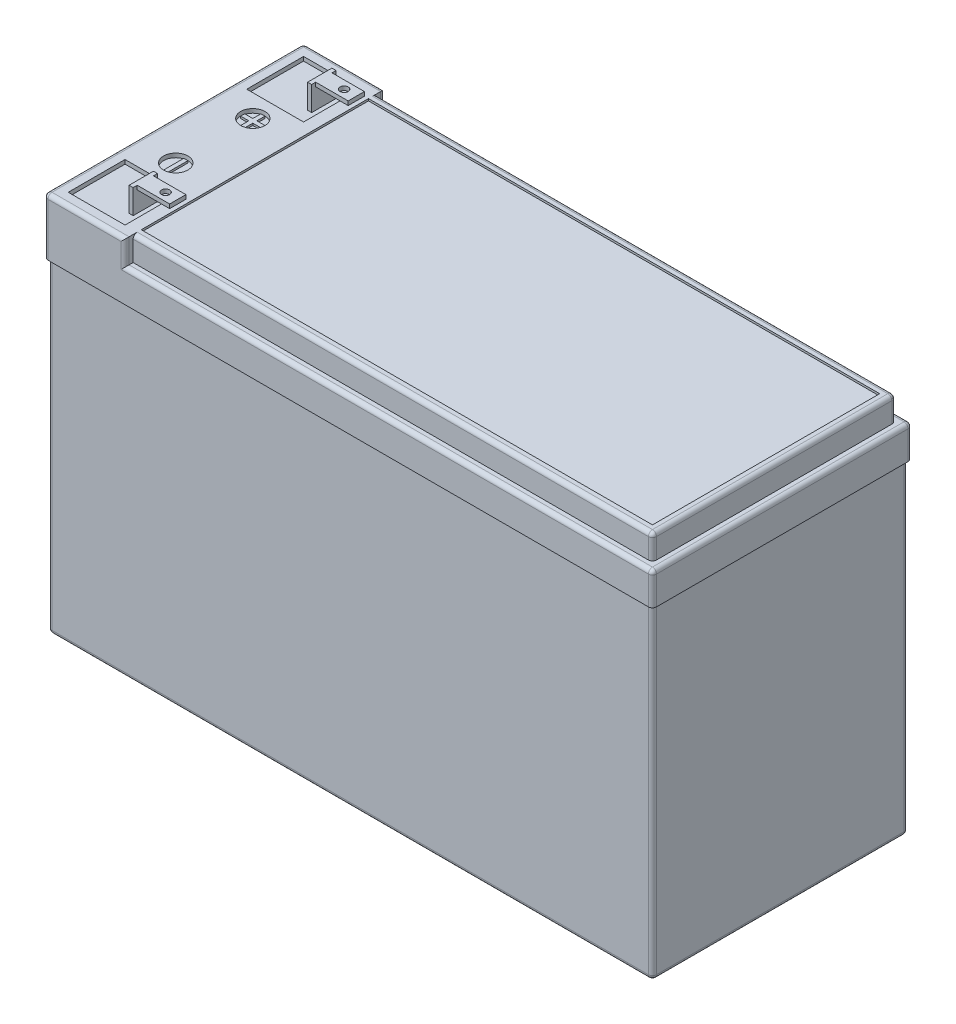
from build123d import *

# Parameters (mm, degrees)
SKETCH1_W           = 150
SKETCH1_H           = 64
BOSS_EXTRUDE1_DEPTH = 94
SKETCH2_W           = 64
SKETCH2_H           = 6
CUT_EXTRUDE1_DEPTH  = 2
CUT_EXTRUDE2_DEPTH  = 2
SKETCH4_W           = 130
SKETCH4_H           = 6
CUT_EXTRUDE3_DEPTH  = 2
SKETCH5_W           = 126
SKETCH5_H           = 56
CUT_EXTRUDE4_DEPTH  = 0.5
SKETCH6_W           = 14
SKETCH6_H           = 14
CUT_EXTRUDE5_DEPTH  = 1
SKETCH7_W           = 1
SKETCH7_H           = 6
BOSS_EXTRUDE2_DEPTH = 6
SKETCH8_W           = 4
SKETCH8_H           = 1
BOSS_EXTRUDE3_DEPTH = 8
SKETCH9_R           = 1
CUT_EXTRUDE6_DEPTH  = 1
SKETCH13_W          = 64
SKETCH13_H          = 80
CUT_EXTRUDE7_DEPTH  = 0.5
SKETCH14_W          = 149.5
SKETCH14_H          = 80
CUT_EXTRUDE8_DEPTH  = 0.5
SKETCH15_W          = 149.5
SKETCH15_H          = 80
CUT_EXTRUDE9_DEPTH  = 0.5
SKETCH16_W          = 63
SKETCH16_H          = 80
CUT_EXTRUDE10_DEPTH = 0.5
SKETCH17_R          = 3
CUT_EXTRUDE11_DEPTH = 1
SKETCH18_W          = 1
SKETCH18_H          = 5
BOSS_EXTRUDE4_DEPTH = 0.5
FILLET4_R           = 1
FILLET5_R           = 1


with BuildPart() as part:
    # Sketch1 → Boss-Extrude1 (new body)
    with BuildSketch(Plane(origin=(0, 0, 0), x_dir=(1, 0, 0), z_dir=(0, 1, 0))):
        Rectangle(SKETCH1_W, SKETCH1_H)
    extrude(amount=BOSS_EXTRUDE1_DEPTH)

    # Sketch2 → Cut-Extrude1 (cut)
    with BuildSketch(Plane(origin=(75, 0, 0), x_dir=(0, 0, -1), z_dir=(1, 0, 0))):
        with Locations((0, 91)):
            Rectangle(SKETCH2_W, SKETCH2_H)
    extrude(amount=-CUT_EXTRUDE1_DEPTH, mode=Mode.SUBTRACT)

    # Sketch3 → Cut-Extrude2 (cut)
    with BuildSketch(Plane(origin=(0, 0, -32), x_dir=(-1, 0, 0), z_dir=(0, 0, -1))):
        Polygon((-73, 88), (55, 88), (55, 94), (-73, 94), (-75, 94), (-75, 88), align=None)
    extrude(amount=-CUT_EXTRUDE2_DEPTH, mode=Mode.SUBTRACT)

    # Sketch4 → Cut-Extrude3 (cut)
    with BuildSketch(Plane.XY.offset(32)):
        with Locations((10, 91)):
            Rectangle(SKETCH4_W, SKETCH4_H)
    extrude(amount=-CUT_EXTRUDE3_DEPTH, mode=Mode.SUBTRACT)

    # Sketch5 → Cut-Extrude4 (cut)
    with BuildSketch(Plane(origin=(0, 94, 0), x_dir=(1, 0, 0), z_dir=(0, 1, 0))):
        with Locations((8, 0)):
            Rectangle(SKETCH5_W, SKETCH5_H)
    extrude(amount=-CUT_EXTRUDE4_DEPTH, mode=Mode.SUBTRACT)

    # Sketch6 → Cut-Extrude5 (cut)
    with BuildSketch(Plane(origin=(0, 94, 0), x_dir=(1, 0, 0), z_dir=(0, 1, 0))):
        with Locations((-65, -22)):
            Rectangle(SKETCH6_W, SKETCH6_H)
        with Locations((-65, 22)):
            Rectangle(SKETCH6_W, SKETCH6_H)
    extrude(amount=-CUT_EXTRUDE5_DEPTH, mode=Mode.SUBTRACT)

    # Sketch7 → Boss-Extrude2 (add)
    with BuildSketch(Plane(origin=(0, 93, 0), x_dir=(1, 0, 0), z_dir=(0, 1, 0))):
        with Locations((-60.5, 22)):
            Rectangle(SKETCH7_W, SKETCH7_H)
        with Locations((-60.5, -22)):
            Rectangle(SKETCH7_W, SKETCH7_H)
    extrude(amount=BOSS_EXTRUDE2_DEPTH)

    # Sketch8 → Boss-Extrude3 (add)
    with BuildSketch(Plane(origin=(-60, 0, 0), x_dir=(0, 0, -1), z_dir=(1, 0, 0))):
        with Locations((-22, 98.5)):
            Rectangle(SKETCH8_W, SKETCH8_H)
        with Locations((22, 98.5)):
            Rectangle(SKETCH8_W, SKETCH8_H)
    extrude(amount=BOSS_EXTRUDE3_DEPTH)

    # Sketch9 → Cut-Extrude6 (cut)
    with BuildSketch(Plane(origin=(0, 99, 0), x_dir=(1, 0, 0), z_dir=(0, 1, 0))):
        with Locations((-55, 22)):
            Circle(SKETCH9_R)
        with Locations((-55, -22)):
            Circle(SKETCH9_R)
    extrude(amount=-CUT_EXTRUDE6_DEPTH, mode=Mode.SUBTRACT)

    # Sketch13 → Cut-Extrude7 (cut)
    with BuildSketch(Plane(origin=(75, 0, 0), x_dir=(0, 0, -1), z_dir=(1, 0, 0))):
        with Locations((0, 40)):
            Rectangle(SKETCH13_W, SKETCH13_H)
    extrude(amount=-CUT_EXTRUDE7_DEPTH, mode=Mode.SUBTRACT)

    # Sketch14 → Cut-Extrude8 (cut)
    with BuildSketch(Plane.XY.offset(32)):
        with Locations((-0.25, 40)):
            Rectangle(SKETCH14_W, SKETCH14_H)
    extrude(amount=-CUT_EXTRUDE8_DEPTH, mode=Mode.SUBTRACT)

    # Sketch15 → Cut-Extrude9 (cut)
    with BuildSketch(Plane(origin=(0, 0, -32), x_dir=(-1, 0, 0), z_dir=(0, 0, -1))):
        with Locations((0.25, 40)):
            Rectangle(SKETCH15_W, SKETCH15_H)
    extrude(amount=-CUT_EXTRUDE9_DEPTH, mode=Mode.SUBTRACT)

    # Sketch16 → Cut-Extrude10 (cut)
    with BuildSketch(Plane.ZY.offset(75)):
        with Locations((0, 40)):
            Rectangle(SKETCH16_W, SKETCH16_H)
    extrude(amount=-CUT_EXTRUDE10_DEPTH, mode=Mode.SUBTRACT)

    # Sketch17 → Cut-Extrude11 (cut)
    with BuildSketch(Plane(origin=(0, 94, 0), x_dir=(1, 0, 0), z_dir=(0, 1, 0))):
        with Locations((-65, 9.5)):
            Circle(SKETCH17_R)
        with Locations((-65, -9.5)):
            Circle(SKETCH17_R)
    extrude(amount=-CUT_EXTRUDE11_DEPTH, mode=Mode.SUBTRACT)

    # Sketch18 → Boss-Extrude4 (add)
    with BuildSketch(Plane(origin=(0, 93, 0), x_dir=(1, 0, 0), z_dir=(0, 1, 0))):
        Polygon((-65.5, 12), (-64.5, 12), (-64.5, 10), (-62.5, 10), (-62.5, 9), (-64.5, 9), (-64.5, 7), (-65.5, 7), (-65.5, 9), (-67.5, 9), (-67.5, 10), (-65.5, 10), align=None)
        with Locations((-65, -9.5)):
            Rectangle(SKETCH18_W, SKETCH18_H)
    extrude(amount=BOSS_EXTRUDE4_DEPTH)

    # Fillet4
    fillet4_edges = [part.edges().sort_by_distance(p)[0] for p in [
        (74.5, 0, 0),
        (74.5, 40, 31.5),
        (74.5, 40, -31.5),
        (0, 0, -31.5),
        (0, 0, 31.5),
        (-74.5, 40, 31.5),
        (-74.5, 0, 0),
        (-74.5, 40, -31.5),
    ]]
    fillet(fillet4_edges, radius=FILLET4_R)

    # Fillet5
    fillet5_edges = [part.edges().sort_by_distance(p)[0] for p in [
        (-75, 94, 0),
        (-65, 94, 32),
        (75, 84, 32),
        (75, 84, -32),
        (10, 88, -32),
        (10, 88, 32),
        (75, 88, 0),
        (73, 94, 0),
        (73, 91, -30),
        (-65, 94, -32),
        (9, 94, -30),
        (-55, 91, -32),
        (73, 91, 30),
        (9, 94, 30),
        (-55, 91, 32),
        (-75, 87, 32),
        (-75, 87, -32),
    ]]
    fillet(fillet5_edges, radius=FILLET5_R)


solid = part.part
